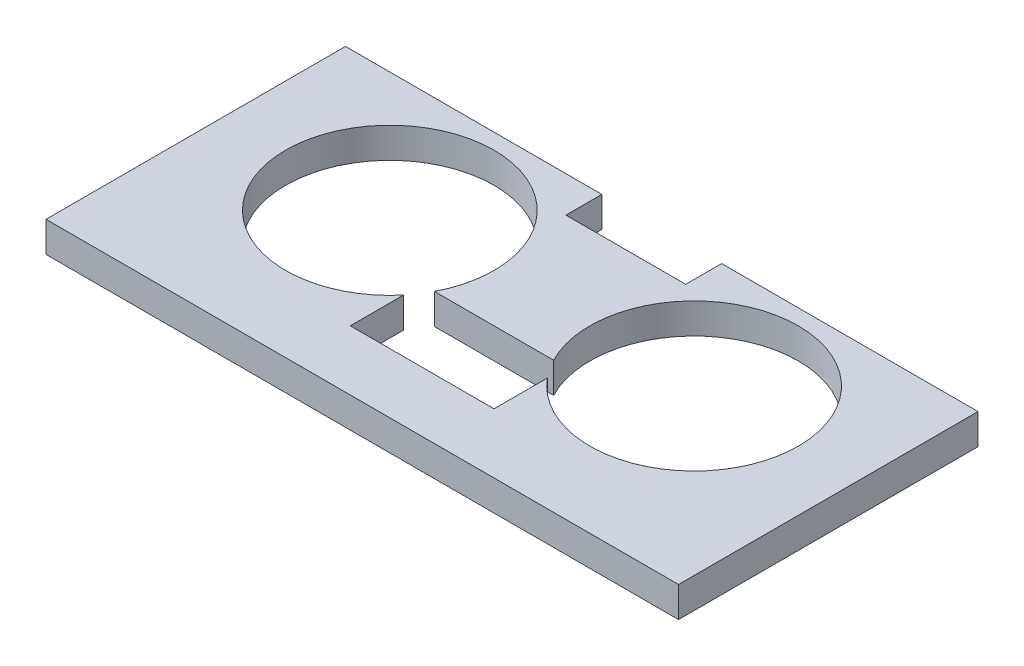
from build123d import *

# Parameters (mm, degrees)
BOSS_EXTRUDE1_DEPTH = 2.54


with BuildPart() as part:
    # Sketch1 → Boss-Extrude1 (new body)
    with BuildSketch(Plane(origin=(0, 0, 0), x_dir=(1, 0, 0), z_dir=(0, 1, 0))):
        Polygon((0.6, 11.5), (-20.8, 11.5), (-20.8, -13.5), (32, -13.5), (32, 11.5), (10.6, 11.5), (10.6, 8.5), (0.6, 8.5), align=None)
        with BuildLine():
            Line((11.6, -8.5), (-0.4, -8.5))
            Line((-0.4, -8.5), (-0.4, -4.04977477))
            ThreePointArc((-0.4, -4.04977477), (-15.284741902, 4.449576241), (1.6, 1.5))
            ThreePointArc((1.6, 1.5), (1.352975635, -0.558446724), (0.625930365, -2.5))
            Line((0.625930365, -2.5), (10.574069635, -2.5))
            ThreePointArc((10.574069635, -2.5), (16.241553276, 9.952975635), (27, 1.5))
            ThreePointArc((27, 1.5), (21.249576241, -6.684741902), (11.6, -4.04977477))
            Line((11.6, -4.04977477), (11.6, -8.5))
        make_face(mode=Mode.SUBTRACT)
    extrude(amount=BOSS_EXTRUDE1_DEPTH)


solid = part.part
